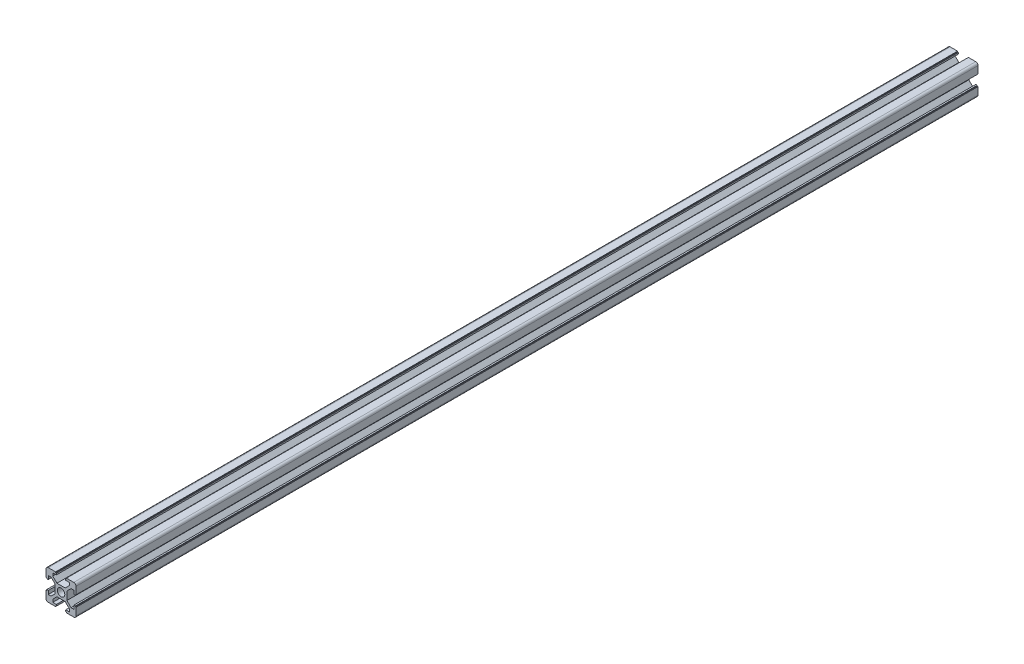
from build123d import *

# Parameters (mm, degrees)
SKETCH_1_R      = 2.5
EXTRUDE_1_DEPTH = 600


with BuildPart() as part:
    # 草图1 → 凸台-拉伸1 (new body)
    with BuildSketch(Plane.XY):
        with BuildLine():
            Line((-3.6, 10), (-3.6, 9.5))
            Line((-3.6, 9.5), (-3.1, 9.5))
            Line((-3.1, 9.5), (-3.1, 8.5))
            Line((-3.1, 8.5), (-5.5, 8.5))
            Line((-5.5, 8.5), (-5.5, 6.65))
            Line((-5.5, 6.65), (-2.75, 3.9))
            Line((-2.75, 3.9), (2.75, 3.9))
            Line((2.75, 3.9), (5.5, 6.65))
            Line((5.5, 6.65), (5.5, 8.5))
            Line((5.5, 8.5), (3.1, 8.5))
            Line((3.1, 8.5), (3.1, 9.5))
            Line((3.1, 9.5), (3.6, 9.5))
            Line((3.6, 9.5), (3.6, 10))
            Line((3.6, 10), (8.5, 10))
            ThreePointArc((8.5, 10), (9.560660172, 9.560660172), (10, 8.5))
            Line((10, 8.5), (10, 3.6))
            Line((10, 3.6), (9.5, 3.6))
            Line((9.5, 3.6), (9.5, 3.1))
            Line((9.5, 3.1), (8.5, 3.1))
            Line((8.5, 3.1), (8.5, 5.5))
            Line((8.5, 5.5), (6.65, 5.5))
            Line((6.65, 5.5), (3.9, 2.75))
            Line((3.9, 2.75), (3.9, -2.75))
            Line((3.9, -2.75), (6.65, -5.5))
            Line((6.65, -5.5), (8.5, -5.5))
            Line((8.5, -5.5), (8.5, -3.1))
            Line((8.5, -3.1), (9.5, -3.1))
            Line((9.5, -3.1), (9.5, -3.6))
            Line((9.5, -3.6), (10, -3.6))
            Line((10, -3.6), (10, -8.5))
            ThreePointArc((10, -8.5), (9.560660172, -9.560660172), (8.5, -10))
            Line((8.5, -10), (3.6, -10))
            Line((3.6, -10), (3.6, -9.5))
            Line((3.6, -9.5), (3.1, -9.5))
            Line((3.1, -9.5), (3.1, -8.5))
            Line((3.1, -8.5), (5.5, -8.5))
            Line((5.5, -8.5), (5.5, -6.65))
            Line((5.5, -6.65), (2.75, -3.9))
            Line((2.75, -3.9), (-2.75, -3.9))
            Line((-2.75, -3.9), (-5.5, -6.65))
            Line((-5.5, -6.65), (-5.5, -8.5))
            Line((-5.5, -8.5), (-3.1, -8.5))
            Line((-3.1, -8.5), (-3.1, -9.5))
            Line((-3.1, -9.5), (-3.6, -9.5))
            Line((-3.6, -9.5), (-3.6, -10))
            Line((-3.6, -10), (-8.5, -10))
            ThreePointArc((-8.5, -10), (-9.560660172, -9.560660172), (-10, -8.5))
            Line((-10, -8.5), (-10, -3.6))
            Line((-10, -3.6), (-9.5, -3.6))
            Line((-9.5, -3.6), (-9.5, -3.1))
            Line((-9.5, -3.1), (-8.5, -3.1))
            Line((-8.5, -3.1), (-8.5, -5.5))
            Line((-8.5, -5.5), (-6.65, -5.5))
            Line((-6.65, -5.5), (-3.9, -2.75))
            Line((-3.9, -2.75), (-3.9, 2.75))
            Line((-3.9, 2.75), (-6.65, 5.5))
            Line((-6.65, 5.5), (-8.5, 5.5))
            Line((-8.5, 5.5), (-8.5, 3.1))
            Line((-8.5, 3.1), (-9.5, 3.1))
            Line((-9.5, 3.1), (-9.5, 3.6))
            Line((-9.5, 3.6), (-10, 3.6))
            Line((-10, 3.6), (-10, 8.5))
            ThreePointArc((-10, 8.5), (-9.560660172, 9.560660172), (-8.5, 10))
            Line((-8.5, 10), (-3.6, 10))
        make_face()
        Circle(SKETCH_1_R, mode=Mode.SUBTRACT)
    extrude(amount=EXTRUDE_1_DEPTH)


solid = part.part
